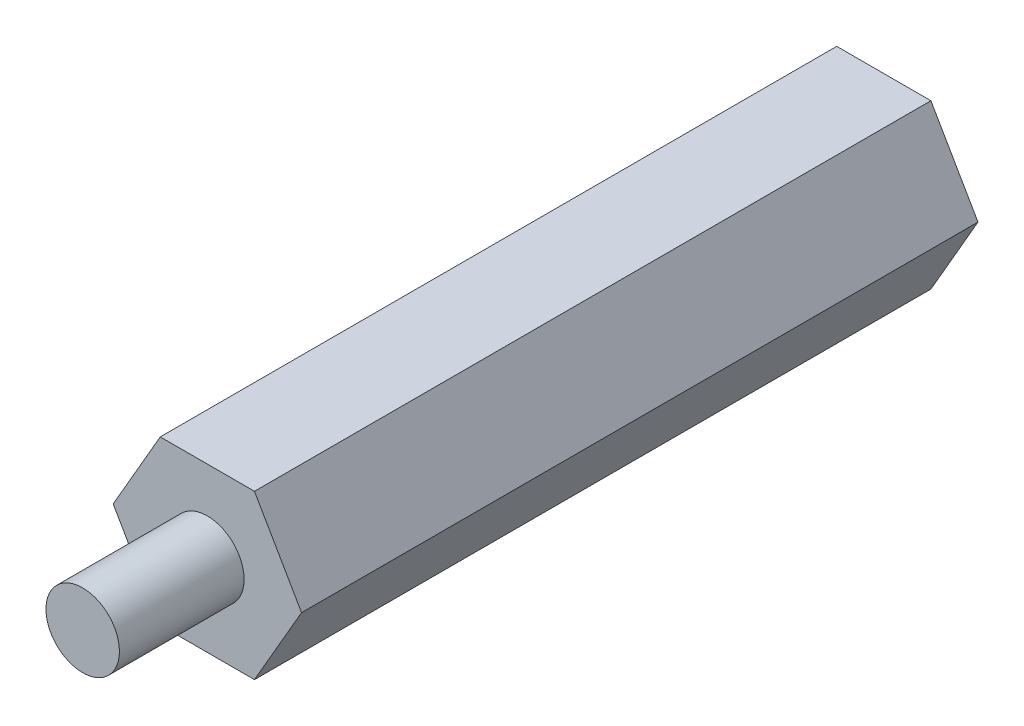
from build123d import *

# Parameters (mm, degrees)
BOSS_EXTRU_1_DEPTH      = 25.5
ESQUISSE2_R             = 1.385
BOSS_EXTRU_2_DEPTH      = 4.7
ESQUISSE3_R             = 1.35
ENL_V_MAT_EXTRU_1_DEPTH = 4.7


with BuildPart() as part:
    # Esquisse1 → Boss.-Extru.1 (new body)
    with BuildSketch(Plane.XY):
        Polygon((3.550704156, 0), (1.775352078, 3.075), (-1.775352078, 3.075), (-3.550704156, 0), (-1.775352078, -3.075), (1.775352078, -3.075), align=None)
    extrude(amount=BOSS_EXTRU_1_DEPTH)

    # Esquisse2 → Boss.-Extru.2 (add)
    with BuildSketch(Plane.XY.offset(25.5)):
        Circle(ESQUISSE2_R)
    extrude(amount=BOSS_EXTRU_2_DEPTH)

    # Esquisse3 → Enlèv. mat.-Extru.1 (cut)
    with BuildSketch(Plane(origin=(0, 0, 0), x_dir=(-1, 0, 0), z_dir=(0, 0, -1))):
        Circle(ESQUISSE3_R)
    extrude(amount=-ENL_V_MAT_EXTRU_1_DEPTH, mode=Mode.SUBTRACT)


solid = part.part
